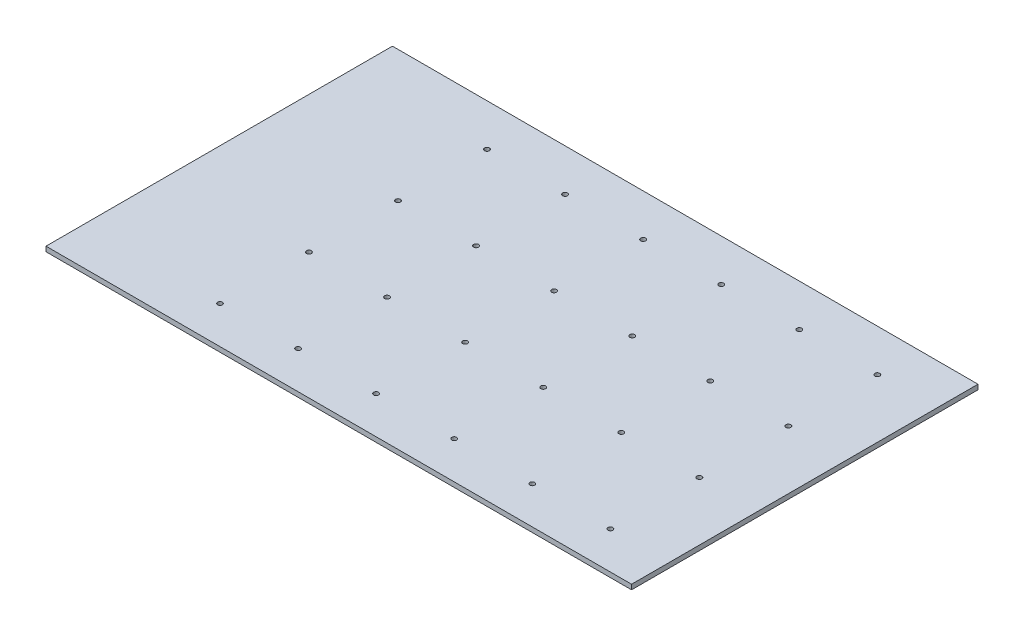
from build123d import *

# Parameters (mm, degrees)
SKETCH1_W           = 762
SKETCH1_H           = 450.85
BOSS_EXTRUDE1_DEPTH = 6.35
SKETCH2_R           = 3.175
CUT_EXTRUDE1_DEPTH  = 6.35


with BuildPart() as part:
    # Sketch1 → Boss-Extrude1 (new body)
    with BuildSketch(Plane(origin=(0, 0, 0), x_dir=(1, 0, 0), z_dir=(0, 1, 0))):
        with Locations((381, 225.425)):
            Rectangle(SKETCH1_W, SKETCH1_H)
    extrude(amount=BOSS_EXTRUDE1_DEPTH)

    # Sketch2 → Cut-Extrude1 (cut)
    with BuildSketch(Plane(origin=(0, 6.35, 0), x_dir=(1, 0, 0), z_dir=(0, 1, 0))):
        with Locations((177.8, 396.0876)):
            Circle(SKETCH2_R)
        with Locations((279.4, 396.0876)):
            Circle(SKETCH2_R)
        with Locations((381, 396.0876)):
            Circle(SKETCH2_R)
        with Locations((482.6, 396.0876)):
            Circle(SKETCH2_R)
        with Locations((177.8, 280.2636)):
            Circle(SKETCH2_R)
        with Locations((279.4, 280.2636)):
            Circle(SKETCH2_R)
        with Locations((381, 280.2636)):
            Circle(SKETCH2_R)
        with Locations((482.6, 280.2636)):
            Circle(SKETCH2_R)
        with Locations((177.8, 164.4396)):
            Circle(SKETCH2_R)
        with Locations((279.4, 164.4396)):
            Circle(SKETCH2_R)
        with Locations((381, 164.4396)):
            Circle(SKETCH2_R)
        with Locations((482.6, 164.4396)):
            Circle(SKETCH2_R)
        with Locations((177.8, 48.6156)):
            Circle(SKETCH2_R)
        with Locations((279.4, 48.6156)):
            Circle(SKETCH2_R)
        with Locations((381, 48.6156)):
            Circle(SKETCH2_R)
        with Locations((482.6, 48.6156)):
            Circle(SKETCH2_R)
        with Locations((584.2, 396.0876)):
            Circle(SKETCH2_R)
        with Locations((685.8, 396.0876)):
            Circle(SKETCH2_R)
        with Locations((584.2, 280.2636)):
            Circle(SKETCH2_R)
        with Locations((685.8, 280.2636)):
            Circle(SKETCH2_R)
        with Locations((584.2, 164.4396)):
            Circle(SKETCH2_R)
        with Locations((685.8, 164.4396)):
            Circle(SKETCH2_R)
        with Locations((584.2, 48.6156)):
            Circle(SKETCH2_R)
        with Locations((685.8, 48.6156)):
            Circle(SKETCH2_R)
    extrude(amount=-CUT_EXTRUDE1_DEPTH, mode=Mode.SUBTRACT)


solid = part.part
